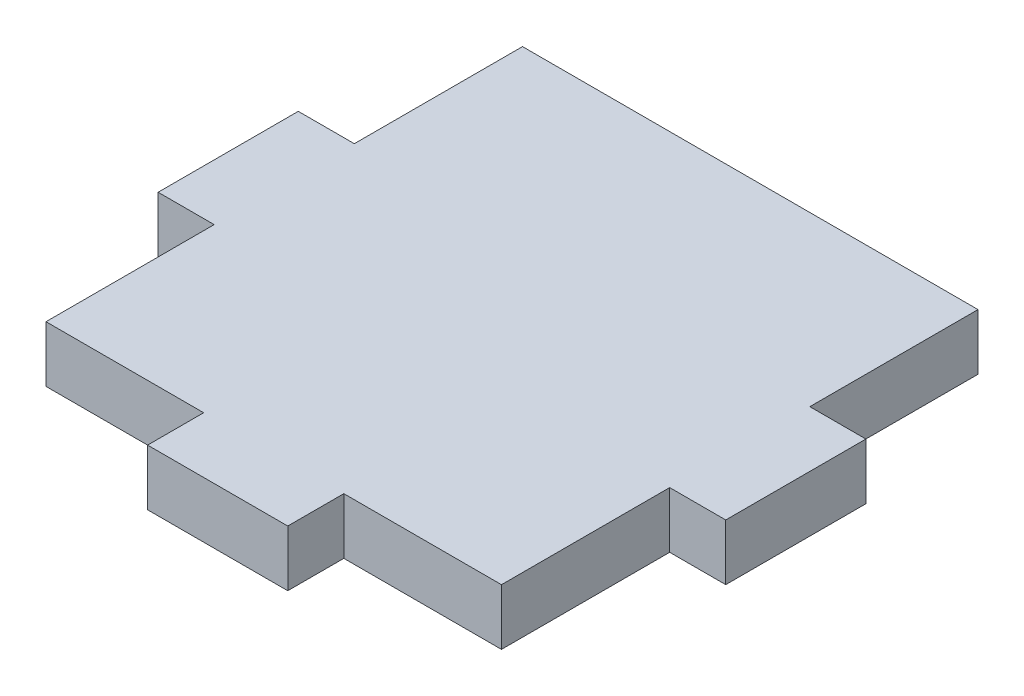
from build123d import *

# Parameters (mm, degrees)
SKETCH1_W           = 32.5
SKETCH1_H           = 34
BOSS_EXTRUDE1_DEPTH = 4
SKETCH2_W           = 10
SKETCH2_H           = 4
SKETCH2_W_2         = 4
SKETCH2_H_2         = 10
BOSS_EXTRUDE2_DEPTH = 4


with BuildPart() as part:
    # Sketch1 → Boss-Extrude1 (new body)
    with BuildSketch(Plane(origin=(0, 0, 0), x_dir=(1, 0, 0), z_dir=(0, 1, 0))):
        with Locations((16.25, -17)):
            Rectangle(SKETCH1_W, SKETCH1_H)
    extrude(amount=BOSS_EXTRUDE1_DEPTH)

    # Sketch2 → Boss-Extrude2 (add, through all)
    with BuildSketch(Plane.XZ):
        with Locations((16.25, 36)):
            Rectangle(SKETCH2_W, SKETCH2_H)
        with Locations((34.5, 17)):
            Rectangle(SKETCH2_W_2, SKETCH2_H_2)
        with Locations((-2, 17)):
            Rectangle(SKETCH2_W_2, SKETCH2_H_2)
    extrude(amount=-BOSS_EXTRUDE2_DEPTH)


solid = part.part
